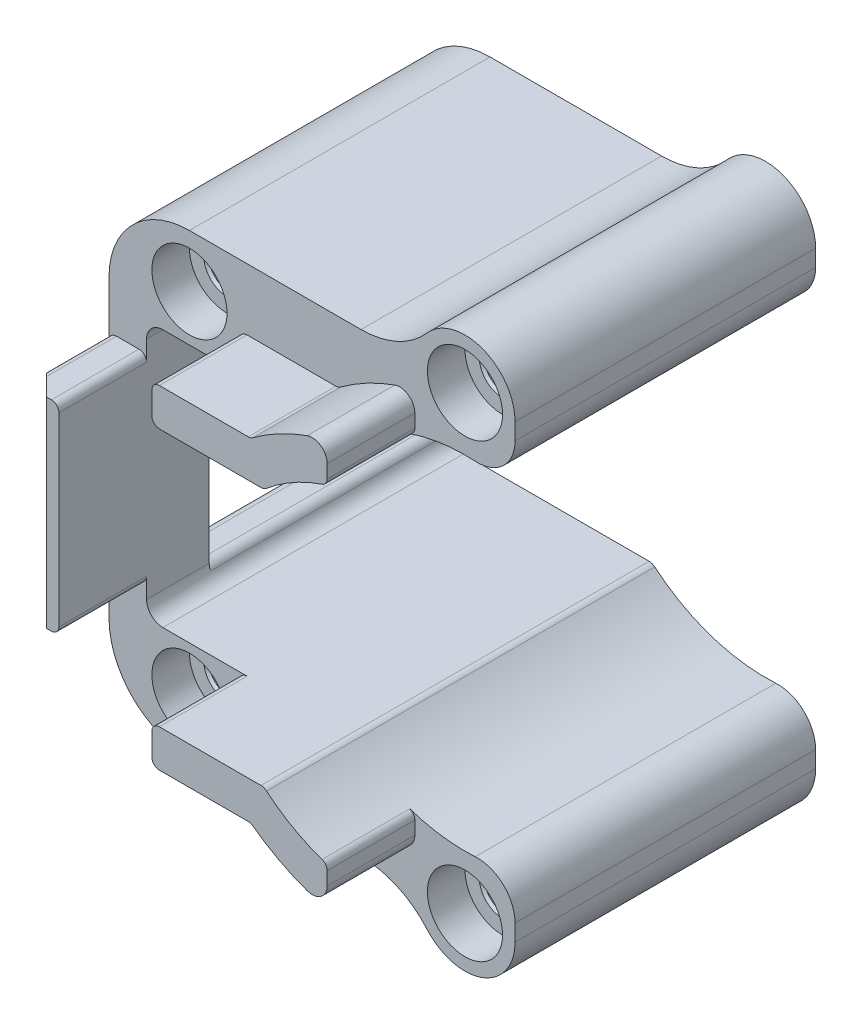
from build123d import *

# Parameters (mm, degrees)
SKETCH1_R             = 1.6499999999999988
SKETCH1_R_2           = 1.6499999999999992
BOSS_EXTRUDE1_DEPTH   = 24
BOSS_EXTRUDE1_2_DEPTH = 24
SKETCH5_R             = 3.0000000000000044
SKETCH5_R_2           = 2.9999999999999996
CUT_EXTRUDE1_DEPTH    = 3
SKETCH6_W             = 2.999999999999975
SKETCH6_H             = 17.999999999999996
BOSS_EXTRUDE2_DEPTH   = 5
FILLET1_R             = 3
BOSS_EXTRUDE3_DEPTH   = 7
CHAMFER1_SIZE         = 2
FILLET2_R             = 0.6
FILLET3_R             = 1.2
CHAMFER2_SIZE         = 0.2
FILLET4_R             = 0.8


with BuildPart() as part:
    # Sketch1 → Boss-Extrude1 (new body)
    with BuildSketch(Plane.XY):
        with BuildLine():
            Line((-24.12157620169872, 10.3), (-9.293008124391159, 10.3))
            ThreePointArc((-9.293008124391159, 10.3), (-9.052493629563461, 10.342616719274229), (-8.841264673899918, 10.465277777777773))
            ThreePointArc((-8.84126467389991, 10.465277777777777), (-2.7566148708280886, 13.419801580274177), (4.000000000000017, 13.103053079339933))
            Line((4.000000000000019, 13.103053079339944), (4.000000000000019, 18))
            ThreePointArc((4.0000000000000195, 18), (1.4019415263376545, 21.7462728086366), (-3.0172799783650257, 20.626027709708623))
            ThreePointArc((-3.017279978365025, 20.626027709708623), (-5.396557983146459, 18.850985983990057), (-8.297519940503818, 18.221576201698717))
            Line((-8.297519940503818, 18.22157620169872), (-22, 18.221576201698717))
            ThreePointArc((-22, 18.221576201698717), (-26.540740078127286, 16.340740078127293), (-28.42157620169869, 11.799999999999997))
            Line((-28.42157620169869, 11.799999999999997), (-28.421576201698695, 8.999999999999998))
            Line((-28.421576201698695, 8.999999999999998), (-25.42157620169872, 8.999999999999998))
            ThreePointArc((-25.42157620169872, 8.999999999999998), (-25.040815017241233, 9.919238815542512), (-24.12157620169872, 10.3))
        make_face()
        with Locations((-21.999999999999996, 14)):
            Circle(SKETCH1_R, mode=Mode.SUBTRACT)
        with Locations((-6.49e-15, 18)):
            Circle(SKETCH1_R_2, mode=Mode.SUBTRACT)
    extrude(amount=BOSS_EXTRUDE1_DEPTH)


with BuildPart() as body_2:
    # Sketch1 → Boss-Extrude1 2 (new body)
    with BuildSketch(Plane.XY):
        with BuildLine():
            ThreePointArc((-24.12157620169872, -10.299999999999999), (-25.040815017241233, -9.91923881554251), (-25.42157620169872, -8.999999999999998))
            Line((-25.42157620169872, -8.999999999999998), (-28.421576201698723, -8.999999999999998))
            Line((-28.421576201698723, -8.999999999999998), (-28.42157620169872, -11.799999999999997))
            ThreePointArc((-28.42157620169872, -11.799999999999997), (-26.540740078127314, -16.340740078127318), (-21.999999999999996, -18.22157620169873))
            Line((-21.999999999999996, -18.22157620169873), (-8.297519940503813, -18.221576201698728))
            ThreePointArc((-8.297519940503813, -18.221576201698728), (-5.3965579831464545, -18.850985983990064), (-3.0172799783650195, -20.62602770970863))
            ThreePointArc((-3.0172799783650204, -20.62602770970863), (1.4019415263376571, -21.74627280863661), (4.000000000000004, -18))
            Line((4.000000000000004, -18), (4.000000000000004, -13.103053079339944))
            ThreePointArc((4.000000000000004, -13.103053079339945), (-2.756614870828109, -13.41980158027418), (-8.841264673899921, -10.465277777777775))
            ThreePointArc((-8.841264673899923, -10.465277777777775), (-9.052493629563463, -10.342616719274227), (-9.293008124391159, -10.299999999999999))
            Line((-9.293008124391159, -10.299999999999999), (-24.12157620169872, -10.299999999999999))
        make_face()
        with Locations((-21.999999999999996, -14)):
            Circle(SKETCH1_R, mode=Mode.SUBTRACT)
        with Locations((4.53e-15, -18)):
            Circle(SKETCH1_R_2, mode=Mode.SUBTRACT)
    extrude(amount=BOSS_EXTRUDE1_2_DEPTH)


with BuildPart() as cut_extrude1_tool:
    # Sketch5 → Cut-Extrude1 (new body)
    with BuildSketch(Plane.XY.offset(24)):
        with Locations((-21.999999999999996, 14)):
            Circle(SKETCH5_R)
        with Locations((-6.49e-15, 18)):
            Circle(SKETCH5_R_2)
        with Locations((4.53e-15, -18)):
            Circle(SKETCH5_R_2)
        with Locations((-21.999999999999996, -14)):
            Circle(SKETCH5_R)
    extrude(amount=-CUT_EXTRUDE1_DEPTH)


with BuildPart() as part_1:
    add(part.part)

    # Cut-Extrude1: cut by cut_extrude1_tool
    add(cut_extrude1_tool.part, mode=Mode.SUBTRACT)



with BuildPart() as body_2_1:
    add(body_2.part)

    # Cut-Extrude1: cut by cut_extrude1_tool
    add(cut_extrude1_tool.part, mode=Mode.SUBTRACT)


with BuildPart() as part_2:
    add(part_1.part)

    add(body_2_1.part)  # Boss-Extrude2 merges body 2
    # Sketch6 → Boss-Extrude2 (add)
    with BuildSketch(Plane.XY.offset(24)):
        with Locations((-26.921576201698706, 0)):
            Rectangle(SKETCH6_W, SKETCH6_H)
    extrude(amount=-BOSS_EXTRUDE2_DEPTH)

    # Fillet1
    fillet1_edges = [part_2.edges().sort_by_distance(p)[0] for p in [
        (4.000000000000018, 13.103053079339938, 12),
        (4.0000000000000036, -13.103053079339944, 12),
    ]]
    fillet(fillet1_edges, radius=FILLET1_R)

    # Sketch7 → Boss-Extrude3 (add)
    with BuildSketch(Plane.XY.offset(24)):
        Polygon((-28.42157620169872, 8.000000000000004), (-25.42157620169872, 8.000000000000004), (-25.42157620169872, -7.9999999999999964), (-28.421576201698716, -7.9999999999999964), align=None)
        with BuildLine():
            Line((-17.999999999999996, 10.3), (-9.293008124391159, 10.3))
            ThreePointArc((-9.293008124391159, 10.3), (-9.052493629563465, 10.342616719274229), (-8.841264673899923, 10.465277777777771))
            ThreePointArc((-8.841264673899923, 10.465277777777771), (-6.554691773201115, 12.030212623155485), (-4, 13.103053079339944))
            Line((-4, 13.103053079339944), (-3.999999999999999, 16.21388294024599))
            ThreePointArc((-3.999999999999999, 16.21388294024599), (-7.198728243522483, 15.068786005379188), (-10.099504938362077, 13.299999999999999))
            Line((-10.099504938362077, 13.299999999999999), (-17.999999999999996, 13.299999999999999))
            Line((-17.999999999999996, 13.299999999999999), (-17.999999999999996, 10.3))
        make_face()
        with BuildLine():
            Line((-17.999999999999993, -10.300000000000004), (-9.293008124391159, -10.3))
            ThreePointArc((-9.293008124391159, -10.3), (-9.052493629563465, -10.342616719274229), (-8.841264673899923, -10.465277777777771))
            ThreePointArc((-8.841264673899923, -10.465277777777771), (-6.554691773201115, -12.030212623155485), (-4, -13.103053079339944))
            Line((-4, -13.103053079339944), (-3.9999999999999947, -16.21388294024599))
            ThreePointArc((-3.9999999999999947, -16.21388294024599), (-7.198728243522483, -15.068786005379188), (-10.099504938362074, -13.300000000000002))
            Line((-10.099504938362074, -13.300000000000002), (-17.999999999999993, -13.300000000000002))
            Line((-17.999999999999993, -13.300000000000002), (-17.999999999999993, -10.300000000000004))
        make_face()
    extrude(amount=BOSS_EXTRUDE3_DEPTH)

    # Chamfer1
    chamfer1_edges = [part_2.edges().sort_by_distance(p)[0] for p in [
        (-28.42157620169872, 3.55e-15, 31),
    ]]
    chamfer(chamfer1_edges, length=CHAMFER1_SIZE)

    # Fillet2
    fillet2_edges = [part_2.edges().sort_by_distance(p)[0] for p in [
        (-25.42157620169872, -7.9999999999999964, 27.5),
        (-25.42157620169872, 8.000000000000004, 27.5),
        (-17.999999999999996, 13.299999999999999, 27.5),
        (-17.999999999999996, 10.3, 27.5),
        (-3.9999999999999996, 13.103053079339945, 27.5),
        (-10.099504938362077, 13.299999999999999, 27.5),
        (-17.999999999999993, -10.300000000000004, 27.5),
        (-17.999999999999993, -13.300000000000002, 27.5),
        (-10.099504938362076, -13.3, 27.5),
        (-3.9999999999999996, -13.103053079339945, 27.5),
        (-28.421576201698716, -7.9999999999999964, 26.5),
        (-28.42157620169872, 8.000000000000004, 26.499999999999993),
    ]]
    fillet(fillet2_edges, radius=FILLET2_R)

    # Fillet3
    fillet3_edges = [part_2.edges().sort_by_distance(p)[0] for p in [
        (-3.999999999999999, 16.213882940245995, 27.5),
        (-3.9999999999999947, -16.21388294024599, 27.5),
    ]]
    fillet(fillet3_edges, radius=FILLET3_R)

    # Chamfer2
    chamfer2_edges = [part_2.edges().sort_by_distance(p)[0] for p in [
        (-23.649999999999995, 14, 21),
        (-1.6500000000000057, 18, 21),
        (-23.649999999999995, -14, 21),
        (-1.6499999999999948, -18, 21),
    ]]
    chamfer(chamfer2_edges, length=CHAMFER2_SIZE)

    # Fillet4
    fillet4_edges = [part_2.edges().sort_by_distance(p)[0] for p in [
        (-25.42157620169872, 8.999999999999998, 9.5),
        (-28.421576201698695, 8.999999999999998, 9.5),
        (-25.42157620169872, -8.999999999999998, 9.5),
        (-28.421576201698723, -8.999999999999998, 9.5),
    ]]
    fillet(fillet4_edges, radius=FILLET4_R)


solid = part_2.part
